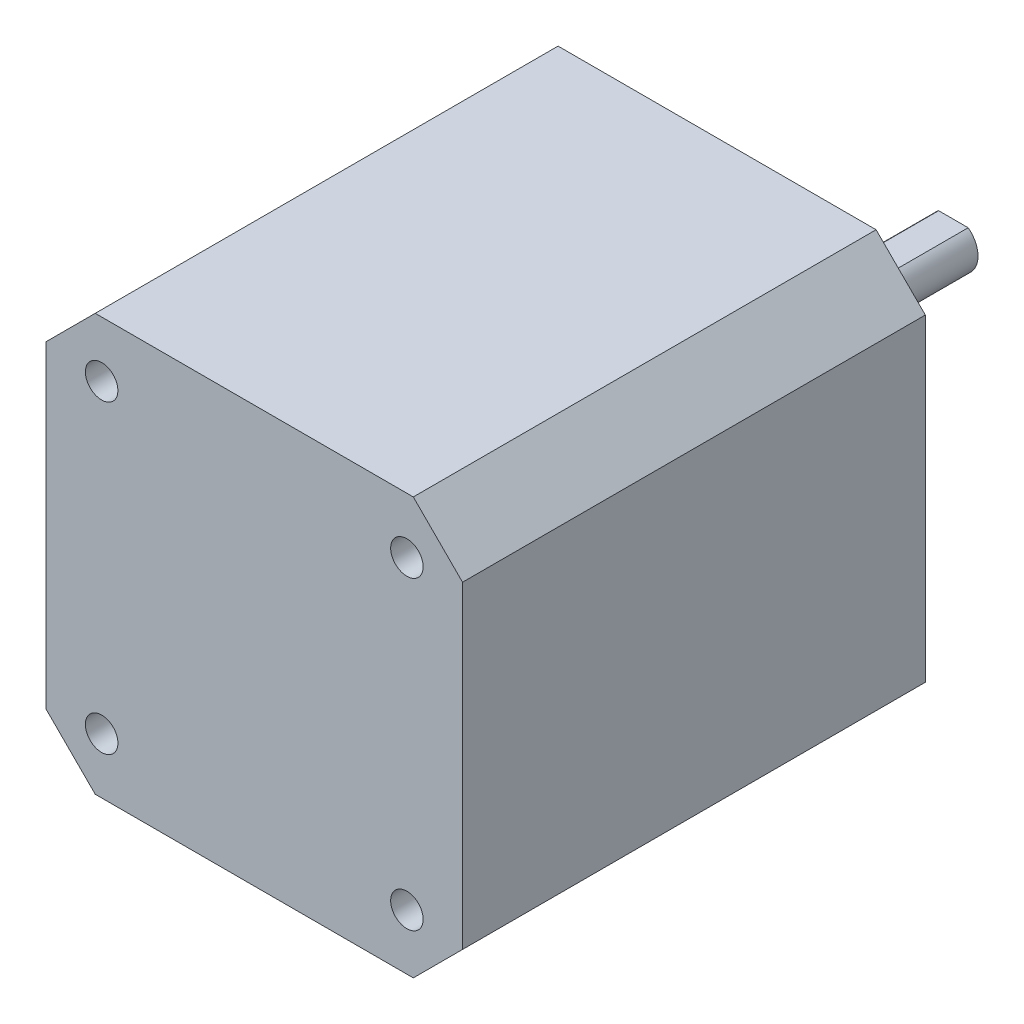
from build123d import *

# Parameters (mm, degrees)
SKETCH_1_R      = 1.65
EXTRUDE_1_DEPTH = 47
SKETCH_3_R      = 11
EXTRUDE_2_DEPTH = 2
EXTRUDE_3_DEPTH = 22


with BuildPart() as part:
    # 草图1 → 凸台-拉伸1 (new body)
    with BuildSketch(Plane.XY):
        Polygon((-21.15, 16.15), (-16.15, 21.15), (16.15, 21.15), (21.15, 16.15), (21.15, -16.15), (16.15, -21.15), (-16.15, -21.15), (-21.15, -16.15), align=None)
        with Locations((15.5, 15.5)):
            Circle(SKETCH_1_R, mode=Mode.SUBTRACT)
        with Locations((-15.5, 15.5)):
            Circle(SKETCH_1_R, mode=Mode.SUBTRACT)
        with Locations((15.5, -15.5)):
            Circle(SKETCH_1_R, mode=Mode.SUBTRACT)
        with Locations((-15.5, -15.5)):
            Circle(SKETCH_1_R, mode=Mode.SUBTRACT)
    extrude(amount=EXTRUDE_1_DEPTH)

    # 草图3 → 凸台-拉伸2 (add)
    with BuildSketch(Plane(origin=(0, 0, 0), x_dir=(-1, 0, 0), z_dir=(0, 0, -1))):
        Circle(SKETCH_3_R)
    extrude(amount=EXTRUDE_2_DEPTH)

    # 草图4 → 凸台-拉伸3 (add)
    with BuildSketch(Plane(origin=(0, 0, -2), x_dir=(-1, 0, 0), z_dir=(0, 0, -1))):
        with BuildLine():
            Line((-1.5, 2), (1.5, 2))
            ThreePointArc((1.5, 2), (0, -2.5), (-1.5, 2))
        make_face()
    extrude(amount=EXTRUDE_3_DEPTH)


solid = part.part
